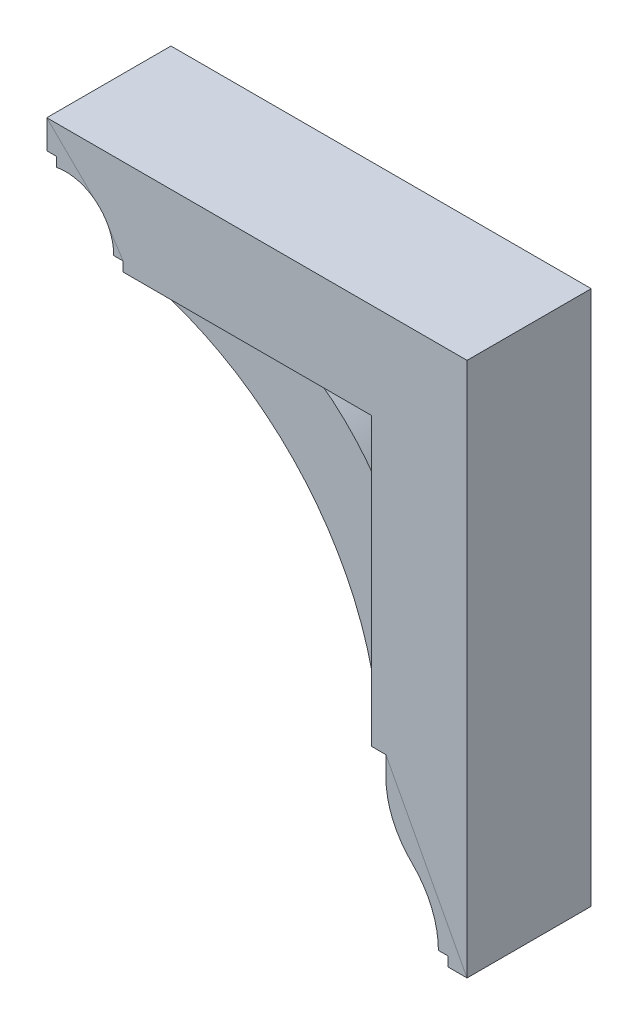
from build123d import *

# Parameters (mm, degrees)
BOSS_EXTRUDE1_DEPTH = 41.275
BOSS_EXTRUDE2_DEPTH = 28.575
BOSS_EXTRUDE3_DEPTH = 41.275


with BuildPart() as part:
    # Sketch1 → Boss-Extrude1 (new body, symmetric)
    with BuildSketch(Plane.XY):
        with BuildLine():
            Line((297.681223016, -285.115), (297.681223016, 70.485))
            Line((297.681223016, 70.485), (18.281223016, 70.485))
            Line((18.281223016, 70.485), (18.281223016, 51.435))
            Line((18.281223016, 51.435), (24.631223016, 51.435))
            Line((24.631223016, 51.435), (24.631223016, 45.085))
            ThreePointArc((24.631223016, 45.085), (51.31358552, 38.368835005), (62.731223016, 13.335))
            Line((62.731223016, 13.335), (69.081223016, 13.335))
            Line((69.081223016, 13.335), (69.081223016, 6.985))
            Line((69.081223016, 6.985), (234.181223016, 6.985))
            Line((234.181223016, 6.985), (234.181223016, -183.515))
            Line((234.181223016, -183.515), (243.706223016, -183.515))
            Line((243.706223016, -183.515), (243.706223016, -196.215))
            ThreePointArc((243.706223016, -196.215), (248.222944617, -218.482925476), (261.059171573, -237.231060226))
            ThreePointArc((261.059171573, -237.231060226), (274.057472101, -256.215913848), (278.631223016, -278.765))
            Line((278.631223016, -278.765), (284.981223016, -278.765))
            Line((284.981223016, -278.765), (284.981223016, -285.115))
            Line((284.981223016, -285.115), (297.681223016, -285.115))
        make_face()
    extrude(amount=BOSS_EXTRUDE1_DEPTH, both=True)


with BuildPart() as body_2:
    # Sketch1_3 → Boss-Extrude2 (new body, symmetric)
    with BuildSketch(Plane.XY):
        with BuildLine():
            Line((221.481223016, -151.765), (234.181223016, -151.765))
            Line((234.181223016, -151.765), (234.181223016, -58.1025))
            ThreePointArc((234.181223016, -58.1025), (207.193723016, -20.912408537), (170.681223016, 6.985))
            Line((170.681223016, 6.985), (88.131223016, 6.985))
            Line((88.131223016, 6.985), (88.131223016, -5.715))
            ThreePointArc((88.131223016, -5.715), (173.773269169, -61.422262208), (221.481223016, -151.765))
        make_face()
    extrude(amount=BOSS_EXTRUDE2_DEPTH, both=True)


with BuildPart() as body_3:
    # Sketch1_4 → Boss-Extrude3 (new body, symmetric)
    with BuildSketch(Plane.XY):
        with BuildLine():
            Line((297.681223016, -285.115), (297.681223016, 70.485))
            Line((297.681223016, 70.485), (18.281223016, 70.485))
            Line((18.281223016, 70.485), (18.281223016, 51.435))
            Line((18.281223016, 51.435), (24.631223016, 51.435))
            Line((24.631223016, 51.435), (24.631223016, 45.085))
            ThreePointArc((24.631223016, 45.085), (51.31358552, 38.368835005), (62.731223016, 13.335))
            Line((62.731223016, 13.335), (69.081223016, 13.335))
            Line((69.081223016, 13.335), (69.081223016, 6.985))
            Line((69.081223016, 6.985), (234.181223016, 6.985))
            Line((234.181223016, 6.985), (234.181223016, -183.515))
            Line((234.181223016, -183.515), (243.706223016, -183.515))
            Line((243.706223016, -183.515), (243.706223016, -196.215))
            ThreePointArc((243.706223016, -196.215), (248.222944617, -218.482925476), (261.059171573, -237.231060226))
            ThreePointArc((261.059171573, -237.231060226), (274.057472101, -256.215913848), (278.631223016, -278.765))
            Line((278.631223016, -278.765), (284.981223016, -278.765))
            Line((284.981223016, -278.765), (284.981223016, -285.115))
            Line((284.981223016, -285.115), (297.681223016, -285.115))
        make_face()
    extrude(amount=BOSS_EXTRUDE3_DEPTH, both=True)


solid = Compound([part.part, body_2.part, body_3.part])
